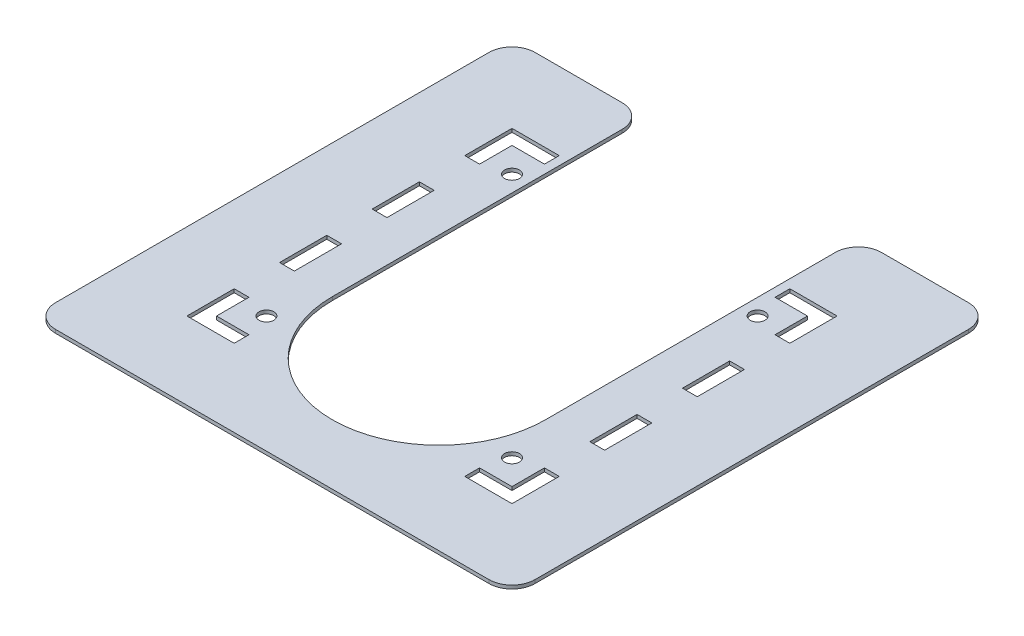
from build123d import *

# Parameters (mm, degrees)
SKETCH1_R           = 1.6
BOSS_EXTRUDE1_DEPTH = 0.75
SKETCH3_W           = 3.2
SKETCH3_H           = 10.21670071
SKETCH3_H_2         = 10.216700711
CUT_EXTRUDE1_DEPTH  = 1.75


with BuildPart() as part:
    # Sketch1 → Boss-Extrude1 (new body)
    with BuildSketch(Plane(origin=(0, 0, 0), x_dir=(1, 0, 0), z_dir=(0, 1, 0))):
        with BuildLine():
            Line((51.872217102, -34.901443346), (51.872217102, 58.842990858))
            ThreePointArc((51.872217102, 58.842990858), (50.407751008, 62.378524764), (46.872217102, 63.842990858))
            Line((46.872217102, 63.842990858), (28.058452488, 63.842990858))
            ThreePointArc((28.058452488, 63.842990858), (24.522918582, 62.378524764), (23.058452488, 58.842990858))
            Line((23.058452488, 58.842990858), (23.058452488, -3.842990858))
            ThreePointArc((23.058452488, -3.842990858), (0, -26.901443346), (-23.058452488, -3.842990858))
            Line((-23.058452488, -3.842990858), (-23.058452488, 58.842990858))
            ThreePointArc((-23.058452488, 58.842990858), (-24.522918582, 62.378524764), (-28.058452488, 63.842990858))
            Line((-28.058452488, 63.842990858), (-46.872217102, 63.842990858))
            ThreePointArc((-46.872217102, 63.842990858), (-50.407751008, 62.378524764), (-51.872217102, 58.842990858))
            Line((-51.872217102, 58.842990858), (-51.872217102, -34.901443346))
            ThreePointArc((-51.872217102, -34.901443346), (-50.407751008, -38.436977252), (-46.872217102, -39.901443346))
            Line((-46.872217102, -39.901443346), (46.872217102, -39.901443346))
            ThreePointArc((46.872217102, -39.901443346), (50.407751008, -38.436977252), (51.872217102, -34.901443346))
        make_face()
        with Locations((26.558452488, -14.587678732)):
            Circle(SKETCH1_R, mode=Mode.SUBTRACT)
        with Locations((-26.558452488, -14.587678732)):
            Circle(SKETCH1_R, mode=Mode.SUBTRACT)
        with Locations((26.558452488, 38.529226244)):
            Circle(SKETCH1_R, mode=Mode.SUBTRACT)
        with Locations((-26.558452488, 38.529226244)):
            Circle(SKETCH1_R, mode=Mode.SUBTRACT)
    extrude(amount=-BOSS_EXTRUDE1_DEPTH)

    # Sketch3 → Cut-Extrude1 (cut, through all)
    with BuildSketch(Plane(origin=(0, 0, 0), x_dir=(1, 0, 0), z_dir=(0, 1, 0))):
        with Locations((33.558452488, 1.954073045)):
            Rectangle(SKETCH3_W, SKETCH3_H)
        Polygon((35.158452488, 36.912525533), (35.158452488, 47.129226244), (24.941751777, 47.129226244), (24.941751777, 43.929226244), (31.958452488, 43.929226244), (31.958452488, 36.912525533), align=None)
        with Locations((33.558452488, 21.987474467)):
            Rectangle(SKETCH3_W, SKETCH3_H_2)
        with Locations((-33.558452488, 21.987474467)):
            Rectangle(SKETCH3_W, SKETCH3_H_2)
        Polygon((-31.958452488, 36.912525533), (-31.958452488, 43.929226244), (-24.941751777, 43.929226244), (-24.941751777, 47.129226244), (-35.158452488, 47.129226244), (-35.158452488, 36.912525533), align=None)
        Polygon((31.958452488, -12.970978021), (31.958452488, -19.987678732), (24.941751777, -19.987678732), (24.941751777, -23.187678732), (35.158452488, -23.187678732), (35.158452488, -12.970978021), align=None)
        Polygon((-35.158452488, -12.970978021), (-35.158452488, -23.187678732), (-24.941751777, -23.187678732), (-24.941751777, -19.987678732), (-31.958452488, -19.987678732), (-31.958452488, -12.970978021), align=None)
        with Locations((-33.558452488, 1.954073045)):
            Rectangle(SKETCH3_W, SKETCH3_H)
    extrude(amount=-CUT_EXTRUDE1_DEPTH, mode=Mode.SUBTRACT)


solid = part.part
